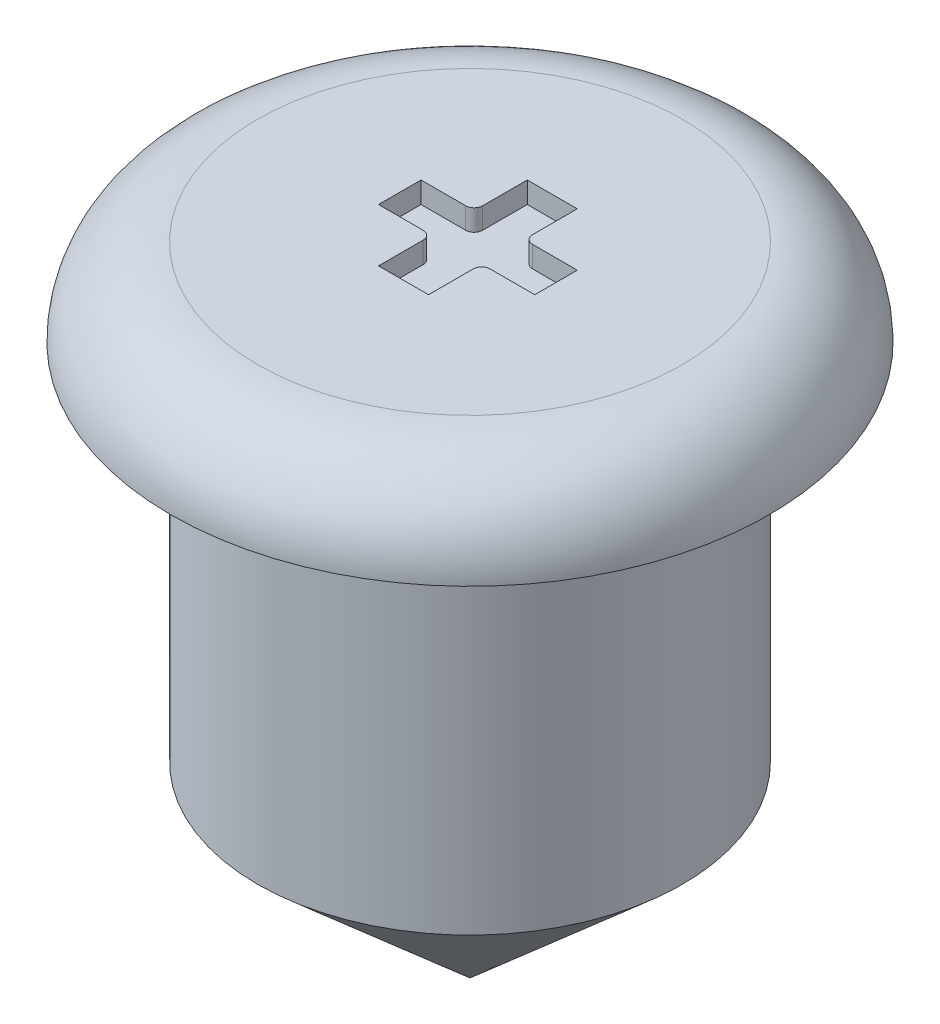
from build123d import *

# Parameters (mm, degrees)
CUT_EXTRUDE1_DEPTH = 0.1


with BuildPart() as part:
    # Sketch1 → Revolve1 (revolve)
    with BuildSketch(Plane.XY):
        with BuildLine():
            Line((1, -15.018131929), (1, -13.308001414))
            Line((1, -13.308001414), (1.408071808, -13.308001414))
            ThreePointArc((1.408071808, -13.308001414), (1.288550343, -13.019451071), (1, -12.899929605))
            Line((1, -12.899929605), (0, -12.899929605))
            Line((0, -12.899929605), (0, -15.899929605))
            Line((0, -15.899929605), (1, -15.018131929))
        make_face()
    revolve(axis=Axis((0, -12.899929605, 0), (0, -1, 0)))

    # Sketch2 → Cut-Extrude1 (cut)
    with BuildSketch(Plane(origin=(0, -12.899929605, 0), x_dir=(1, 0, 0), z_dir=(0, 1, 0))):
        with BuildLine():
            Line((-0.117632759, 0.387224573), (0.117632759, 0.387224573))
            Line((0.117632759, 0.387224573), (0.117632759, 0.177224573))
            ThreePointArc((0.117632759, 0.177224573), (0.129348488, 0.148940302), (0.157632759, 0.137224573))
            Line((0.157632759, 0.137224573), (0.367632759, 0.137224573))
            Line((0.367632759, 0.137224573), (0.367632759, -0.062775427))
            Line((0.367632759, -0.062775427), (0.157632759, -0.062775427))
            ThreePointArc((0.157632759, -0.062775427), (0.129348488, -0.074491156), (0.117632759, -0.102775427))
            Line((0.117632759, -0.102775427), (0.117632759, -0.312775427))
            Line((0.117632759, -0.312775427), (-0.117632759, -0.312775427))
            Line((-0.117632759, -0.312775427), (-0.117632759, -0.102775427))
            ThreePointArc((-0.117632759, -0.102775427), (-0.129348488, -0.074491156), (-0.157632759, -0.062775427))
            Line((-0.157632759, -0.062775427), (-0.367632759, -0.062775427))
            Line((-0.367632759, -0.062775427), (-0.367632759, 0.137224573))
            Line((-0.367632759, 0.137224573), (-0.157632759, 0.137224573))
            ThreePointArc((-0.157632759, 0.137224573), (-0.129348488, 0.148940302), (-0.117632759, 0.177224573))
            Line((-0.117632759, 0.177224573), (-0.117632759, 0.387224573))
        make_face()
    extrude(amount=-CUT_EXTRUDE1_DEPTH, mode=Mode.SUBTRACT)


solid = part.part
